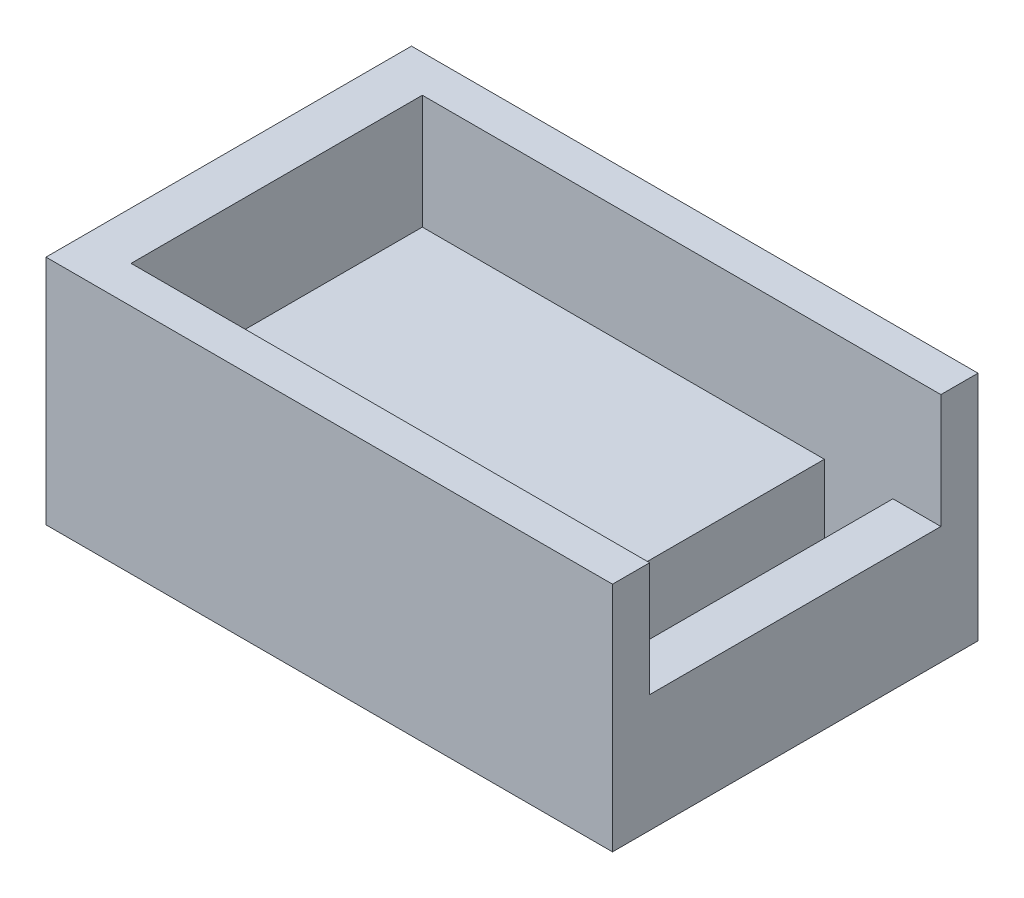
from build123d import *

# Parameters (mm, degrees)
SKETCH2_W           = 24.8
SKETCH2_H           = 16
SKETCH2_W_2         = 3
SKETCH2_H_2         = 12.75
BOSS_EXTRUDE1_DEPTH = 5.15
BOSS_EXTRUDE2_DEPTH = 5


with BuildPart() as part:
    # Sketch2 → Boss-Extrude1 (new body)
    with BuildSketch(Plane(origin=(0, 0, 0), x_dir=(1, 0, 0), z_dir=(0, 1, 0))):
        with Locations((12.4, -8)):
            Rectangle(SKETCH2_W, SKETCH2_H)
        with Locations((21.2, -8)):
            Rectangle(SKETCH2_W_2, SKETCH2_H_2, mode=Mode.SUBTRACT)
    extrude(amount=BOSS_EXTRUDE1_DEPTH)

    # Sketch4 → Boss-Extrude2 (add)
    with BuildSketch(Plane(origin=(0, 5.15, 0), x_dir=(1, 0, 0), z_dir=(0, 1, 0))):
        Polygon((2.1, -1.625), (19.7, -1.625), (22.7, -1.625), (24.8, -1.625), (24.8, 0), (0, 0), (0, -16), (24.8, -16), (24.8, -14.375), (22.7, -14.375), (19.7, -14.375), (2.1, -14.375), align=None)
    extrude(amount=BOSS_EXTRUDE2_DEPTH)


solid = part.part
